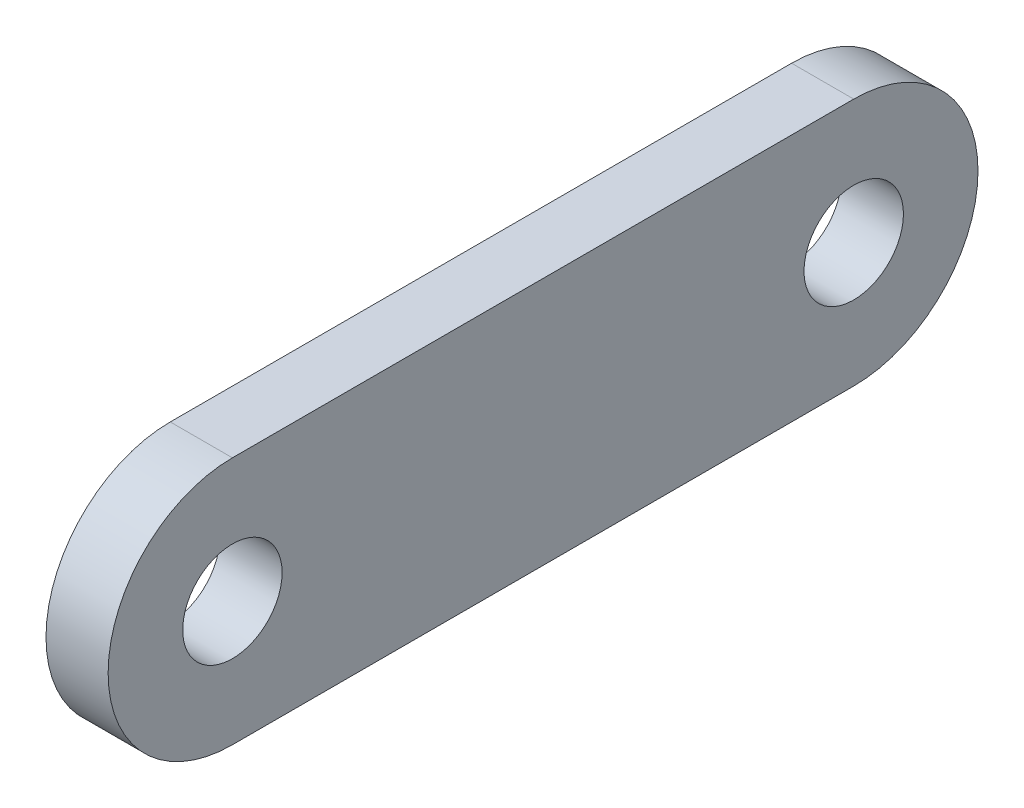
from build123d import *

# Parameters (mm, degrees)
BOSS_EXTRUDE1_DEPTH = 5
SKETCH2_R           = 4
CUT_EXTRUDE1_DEPTH  = 6


with BuildPart() as part:
    # Sketch1 → Boss-Extrude1 (new body)
    with BuildSketch(Plane(origin=(0, 0, 0), x_dir=(0, 0, -1), z_dir=(1, 0, 0))):
        with BuildLine():
            Line((-25, 10), (25, 10))
            ThreePointArc((25, 10), (35, 0), (25, -10))
            Line((25, -10), (-25, -10))
            ThreePointArc((-25, -10), (-35, 0), (-25, 10))
        make_face()
    extrude(amount=BOSS_EXTRUDE1_DEPTH)

    # Sketch2 → Cut-Extrude1 (cut, through all)
    with BuildSketch(Plane(origin=(5, 0, 0), x_dir=(0, 0, -1), z_dir=(1, 0, 0))):
        with Locations((-25, 0)):
            Circle(SKETCH2_R)
        with Locations((25, 0)):
            Circle(SKETCH2_R)
    extrude(amount=-CUT_EXTRUDE1_DEPTH, mode=Mode.SUBTRACT)


solid = part.part
